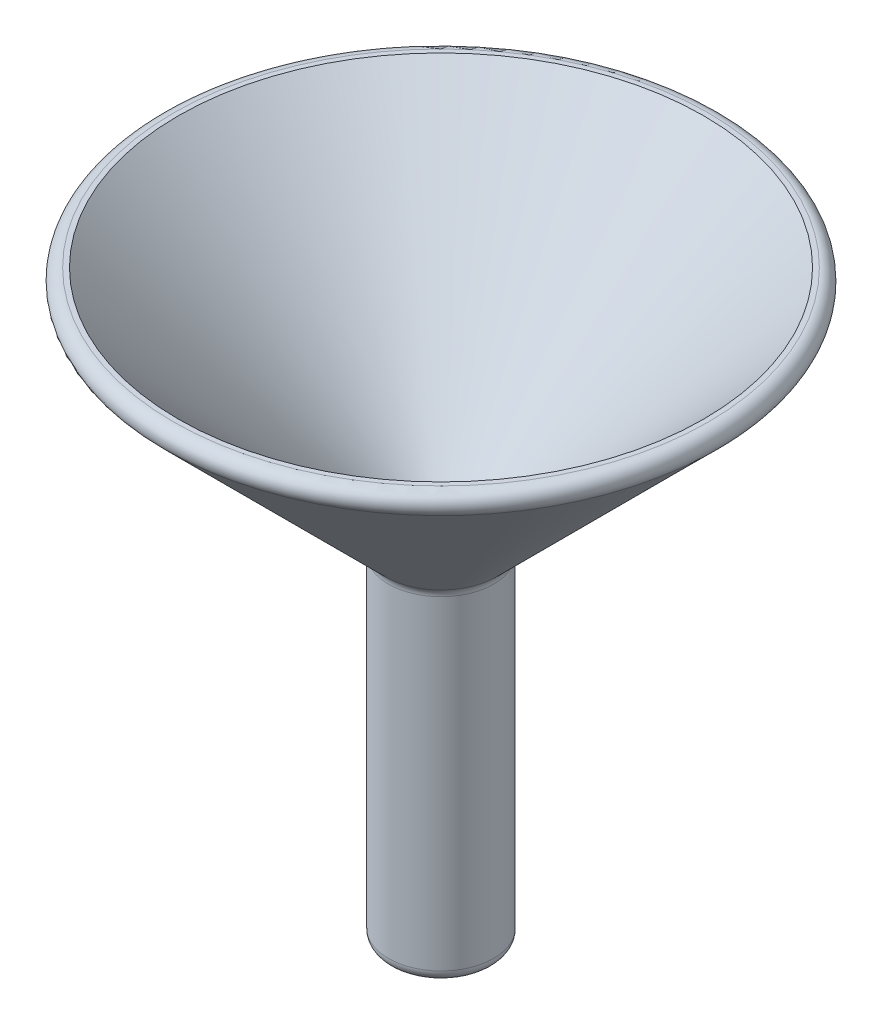
from build123d import *

# Parameters (mm, degrees)
FILLET_1_R = 1


with BuildPart() as part:
    # Эскиз1 → Повернуть1 (revolve)
    with BuildSketch(Plane.XY):
        Polygon((2.5, 0), (2.5, -30), (4.5, -30), (4.5, -0.828427125), (25.328427125, 20), (22.5, 20), align=None)
    revolve(axis=Axis((0, 0, 0), (0, 1, 0)))

    # Скругление1
    fillet_1_edges = [part.edges().sort_by_distance(p)[0] for p in [
        (-4.5, -30, 0),
        (-4.5, -0.828427125, 0),
        (-25.328427125, 20, 0),
    ]]
    fillet(fillet_1_edges, radius=FILLET_1_R)


solid = part.part
